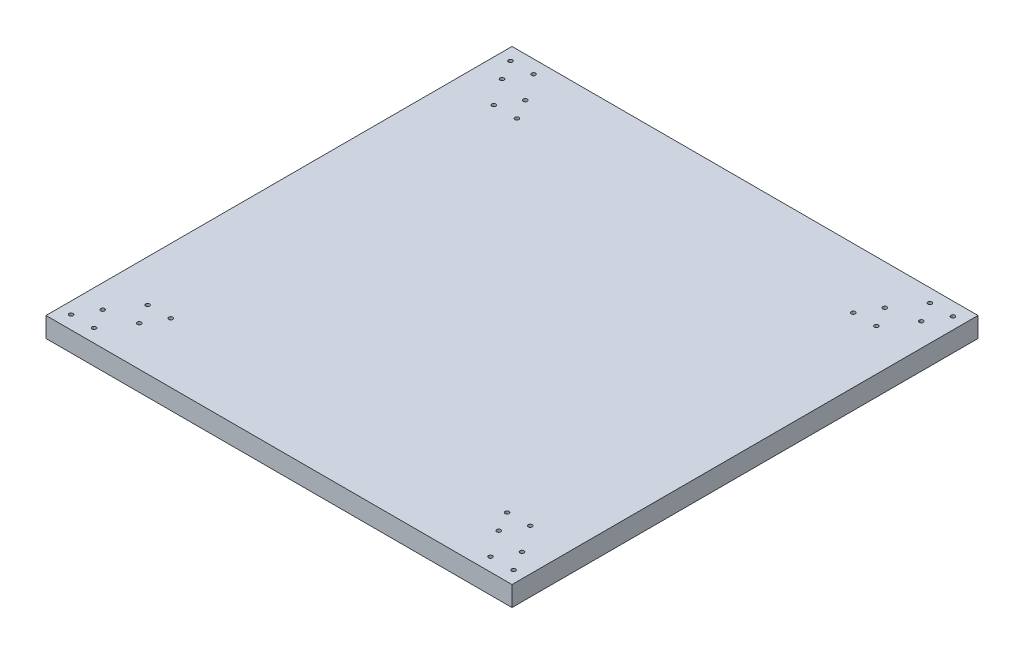
from build123d import *

# Parameters (mm, degrees)
SKETCH2_W           = 350
SKETCH2_H           = 350
SKETCH2_R           = 1.5
BOSS_EXTRUDE1_DEPTH = 15


with BuildPart() as part:
    # Sketch2 → Boss-Extrude1 (new body)
    with BuildSketch(Plane(origin=(0, 0, 0), x_dir=(1, 0, 0), z_dir=(0, 1, 0))):
        with Locations((2.345844504, -68.498659517)):
            Rectangle(SKETCH2_W, SKETCH2_H)
        with Locations((159.845844504, -218.498659517)):
            Circle(SKETCH2_R, mode=Mode.SUBTRACT)
        with Locations((168.506098542, -233.498659517)):
            Circle(SKETCH2_R, mode=Mode.SUBTRACT)
        with Locations((151.185590466, -233.498659517)):
            Circle(SKETCH2_R, mode=Mode.SUBTRACT)
        with Locations((168.506098542, 96.501340483)):
            Circle(SKETCH2_R, mode=Mode.SUBTRACT)
        with Locations((159.845844504, 81.501340483)):
            Circle(SKETCH2_R, mode=Mode.SUBTRACT)
        with Locations((151.185590466, 96.501340483)):
            Circle(SKETCH2_R, mode=Mode.SUBTRACT)
        with Locations((-163.814409534, 96.501340483)):
            Circle(SKETCH2_R, mode=Mode.SUBTRACT)
        with Locations((-146.493901458, 96.501340483)):
            Circle(SKETCH2_R, mode=Mode.SUBTRACT)
        with Locations((-155.154155496, 81.501340483)):
            Circle(SKETCH2_R, mode=Mode.SUBTRACT)
        with Locations((-155.154155496, -218.498659517)):
            Circle(SKETCH2_R, mode=Mode.SUBTRACT)
        with Locations((-146.493901458, -233.498659517)):
            Circle(SKETCH2_R, mode=Mode.SUBTRACT)
        with Locations((-163.814409534, -233.498659517)):
            Circle(SKETCH2_R, mode=Mode.SUBTRACT)
        with Locations((137.345844504, 76.501340483)):
            Circle(SKETCH2_R, mode=Mode.SUBTRACT)
        with Locations((146.006098542, 61.501340483)):
            Circle(SKETCH2_R, mode=Mode.SUBTRACT)
        with Locations((128.685590466, 61.501340483)):
            Circle(SKETCH2_R, mode=Mode.SUBTRACT)
        with Locations((-123.993901458, 61.501340483)):
            Circle(SKETCH2_R, mode=Mode.SUBTRACT)
        with Locations((-141.314409534, 61.501340483)):
            Circle(SKETCH2_R, mode=Mode.SUBTRACT)
        with Locations((-132.654155496, 76.501340483)):
            Circle(SKETCH2_R, mode=Mode.SUBTRACT)
        with Locations((-141.314409534, -198.498659517)):
            Circle(SKETCH2_R, mode=Mode.SUBTRACT)
        with Locations((-123.993901458, -198.498659517)):
            Circle(SKETCH2_R, mode=Mode.SUBTRACT)
        with Locations((-132.654155496, -213.498659517)):
            Circle(SKETCH2_R, mode=Mode.SUBTRACT)
        with Locations((128.685590466, -198.498659517)):
            Circle(SKETCH2_R, mode=Mode.SUBTRACT)
        with Locations((146.006098542, -198.498659517)):
            Circle(SKETCH2_R, mode=Mode.SUBTRACT)
        with Locations((137.345844504, -213.498659517)):
            Circle(SKETCH2_R, mode=Mode.SUBTRACT)
    extrude(amount=BOSS_EXTRUDE1_DEPTH)


solid = part.part
